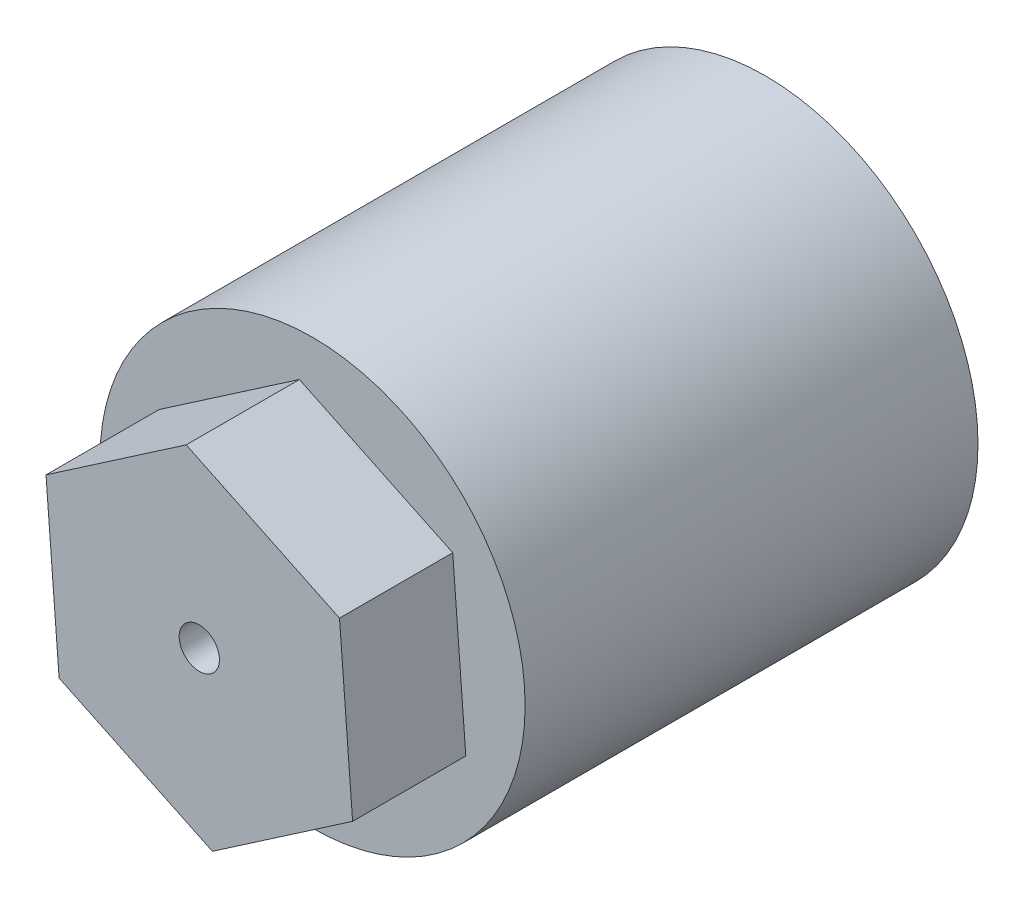
from build123d import *

# Parameters (mm, degrees)
BOSS_EXTRUDE1_DEPTH = 4.5
SKETCH4_R           = 8.45
BOSS_EXTRUDE2_DEPTH = 18
BOSS_EXTRUDE3_DEPTH = 4.5
SKETCH2_R           = 0.8
CUT_EXTRUDE2_DEPTH  = 6.5
BOSS_EXTRUDE4_DEPTH = 4.5
SKETCH2_2_R         = 0.8
CUT_EXTRUDE4_DEPTH  = 6
CUT_EXTRUDE5_DEPTH  = 16


with BuildPart() as part:
    # Sketch1 → Boss-Extrude1 (new body)
    with BuildSketch(Plane.XY):
        Polygon((5.572251372, 3.818378537), (-0.520687129, 6.734900513), (-6.0929385, 2.916521976), (-5.572251372, -3.818378537), (0.520687129, -6.734900513), (6.0929385, -2.916521976), align=None)
    extrude(amount=BOSS_EXTRUDE1_DEPTH)

    # Sketch4 → Boss-Extrude2 (add)
    with BuildSketch(Plane(origin=(0, 0, 0), x_dir=(-1, 0, 0), z_dir=(0, 0, -1))):
        Circle(SKETCH4_R)
    extrude(amount=BOSS_EXTRUDE2_DEPTH)

    # Sketch1_2 → Boss-Extrude3 (add)
    with BuildSketch(Plane.XY):
        Polygon((5.572251372, 3.818378537), (-0.520687129, 6.734900513), (-6.0929385, 2.916521976), (-5.572251372, -3.818378537), (0.520687129, -6.734900513), (6.0929385, -2.916521976), align=None)
    extrude(amount=BOSS_EXTRUDE3_DEPTH)

    # Sketch2 → Cut-Extrude2 (cut)
    with BuildSketch(Plane.XY.offset(4.5)):
        Circle(SKETCH2_R)
    extrude(amount=-CUT_EXTRUDE2_DEPTH, mode=Mode.SUBTRACT)

    # Sketch1_3 → Boss-Extrude4 (add)
    with BuildSketch(Plane.XY):
        Polygon((5.572251372, 3.818378537), (-0.520687129, 6.734900513), (-6.0929385, 2.916521976), (-5.572251372, -3.818378537), (0.520687129, -6.734900513), (6.0929385, -2.916521976), align=None)
    extrude(amount=BOSS_EXTRUDE4_DEPTH)

    # Sketch2_2 → Cut-Extrude4 (cut)
    with BuildSketch(Plane.XY.offset(4.5)):
        Circle(SKETCH2_2_R)
    extrude(amount=-CUT_EXTRUDE4_DEPTH, mode=Mode.SUBTRACT)

    # Sketch5 → Cut-Extrude5 (cut)
    with BuildSketch(Plane(origin=(0, 0, -18), x_dir=(-1, 0, 0), z_dir=(0, 0, -1))):
        with BuildLine():
            Line((-1.965909199, -1.850729862), (1.965909199, -1.850729862))
            ThreePointArc((1.965909199, -1.850729862), (2.7, 0), (1.965909199, 1.850729862))
            Line((1.965909199, 1.850729862), (-1.965909199, 1.850729862))
            ThreePointArc((-1.965909199, 1.850729862), (-2.7, 0), (-1.965909199, -1.850729862))
        make_face()
    extrude(amount=-CUT_EXTRUDE5_DEPTH, mode=Mode.SUBTRACT)


solid = part.part
